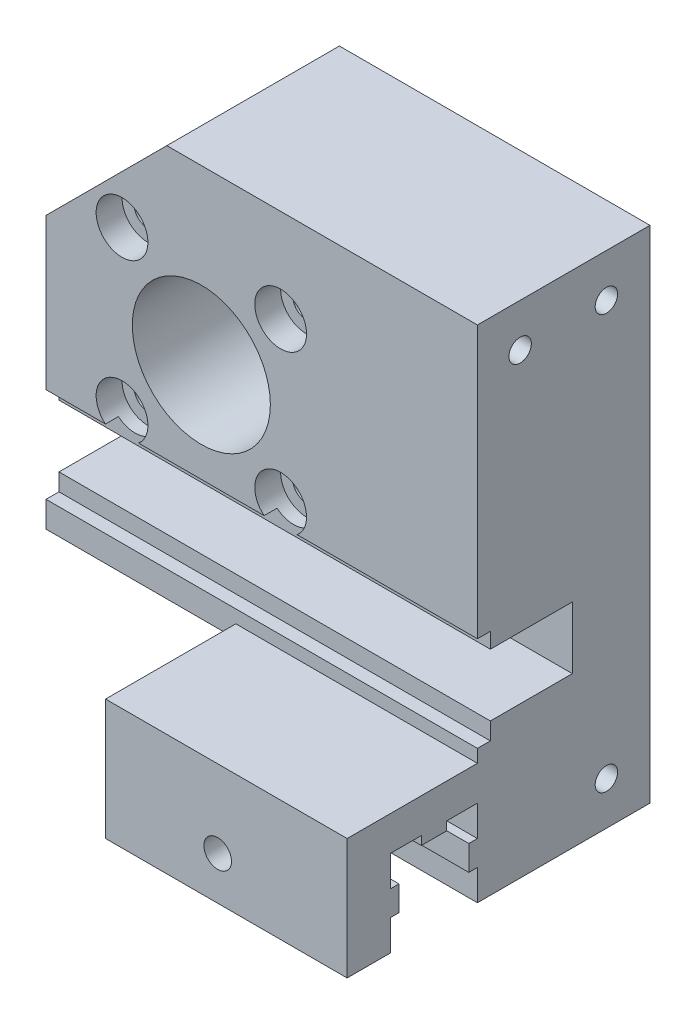
from build123d import *

# Parameters (mm, degrees)
ESQUISSE1_W                     = 50
ESQUISSE1_H                     = 45
MAIN_EXTRUSION_DEPTH            = 20
ESQUISSE5_R                     = 8
GEAR_LINEAR_HOLES_DEPTH         = 21
FIXING_EXTRUSION_DEPTH          = 25
ESQUISSE13_W                    = 50
ESQUISSE13_H                    = 7.2
ROLLINGBALLHORIZONTALHOLE_DEPTH = 11
FRONTHOLE_DEPTH                 = 22
ESQUISSE15_R                    = 1.6
BOTTOMFIXINGHOLE_DEPTH          = 36.1
ESQUISSE12_R                    = 16
REDUCTORMAINHOLE_DEPTH          = 5
REDUCTORFRONTFIXINGHOLE_DEPTH   = 3
ESQUISSE17_R                    = 1.6
MOTORFIXINGHOLE_DEPTH           = 31.1
ESQUISSE19_R                    = 3
ENL_V_MAT_EXTRU_5_DEPTH         = 3
SKETCH2_W                       = 1.5
SKETCH2_H                       = 11
CUTFORMAKERBEAMPROFILE_DEPTH    = 51
CUTFORDISTRIBUTORGRABBER_DEPTH  = 21
SKETCH4_R                       = 1.3
HOLETOBLOCKBEHIND_DEPTH         = 12


with BuildPart() as part:
    # Esquisse1 → Main Extrusion (new body)
    with BuildSketch(Plane.XY):
        Rectangle(ESQUISSE1_W, ESQUISSE1_H)
    extrude(amount=MAIN_EXTRUSION_DEPTH)

    # Esquisse5 → Gear Linear Holes (cut, through all)
    with BuildSketch(Plane.XY.offset(20)):
        with Locations((-7, 2.5)):
            Circle(ESQUISSE5_R)
    extrude(amount=-GEAR_LINEAR_HOLES_DEPTH, mode=Mode.SUBTRACT)

    # Esquisse8 → Fixing Extrusion (add, symmetric)
    with BuildSketch(Plane(origin=(0, 0, 0), x_dir=(0, 0, -1), z_dir=(1, 0, 0))):
        Polygon((-20, -25.5), (-20, -29.05), (-21, -29.05), (-21, -31.95), (-20, -31.95), (-20, -35.5), (0, -35.5), (0, -21.5), (-35.1, -21.5), (-35.1, -35.5), (-30.1, -35.5), (-30.1, -31.95), (-29.1, -31.95), (-29.1, -29.05), (-30.1, -29.05), (-30.1, -25.5), (-26.5, -25.5), (-26.5, -26.5), (-23.6, -26.5), (-23.6, -25.5), align=None)
    extrude(amount=FIXING_EXTRUSION_DEPTH, both=True)

    # Esquisse13 → RollingBallHorizontalHole (cut)
    with BuildSketch(Plane.XY.offset(20)):
        with Locations((0, -14.4)):
            Rectangle(ESQUISSE13_W, ESQUISSE13_H)
    extrude(amount=-ROLLINGBALLHORIZONTALHOLE_DEPTH, mode=Mode.SUBTRACT)

    # Esquisse14 → FrontHole (cut)
    with BuildSketch(Plane.ZY.offset(25)):
        Polygon((0, -23), (20, -23), (20, -18), (35.1, -18), (35.1, -35.5), (0, -35.5), align=None)
    extrude(amount=-FRONTHOLE_DEPTH, mode=Mode.SUBTRACT)

    # Esquisse15 → BottomFixingHole (cut, through all)
    with BuildSketch(Plane.XY.offset(35.1)):
        with Locations((10, -30.5)):
            Circle(ESQUISSE15_R)
    extrude(amount=-BOTTOMFIXINGHOLE_DEPTH, mode=Mode.SUBTRACT)

    # Esquisse12 → ReductorMainHole (cut)
    with BuildSketch(Plane.XY):
        with Locations((-7, 2.5)):
            Circle(ESQUISSE12_R)
    extrude(amount=REDUCTORMAINHOLE_DEPTH, mode=Mode.SUBTRACT)

    # Esquisse16 → ReductorFrontFixingHole (cut)
    with BuildSketch(Plane(origin=(0, 0, 5), x_dir=(-1, 0, 0), z_dir=(0, 0, -1))):
        with BuildLine():
            Line((2.641101056, 11.5), (11.358898944, 11.5))
            ThreePointArc((11.358898944, 11.5), (17, 2.5), (11.358898944, -6.5))
            Line((11.358898944, -6.5), (2.641101056, -6.5))
            ThreePointArc((2.641101056, -6.5), (-3, 2.5), (2.641101056, 11.5))
        make_face()
    extrude(amount=-REDUCTORFRONTFIXINGHOLE_DEPTH, mode=Mode.SUBTRACT)

    # Esquisse17 → MotorFixingHole (cut, through all)
    with BuildSketch(Plane(origin=(0, 0, 5), x_dir=(-1, 0, 0), z_dir=(0, 0, -1))):
        with Locations((-2.192388155, 11.692388155)):
            Circle(ESQUISSE17_R)
        with Locations((16.192388155, 11.692388155)):
            Circle(ESQUISSE17_R)
        with Locations((-2.192388155, -6.692388155)):
            Circle(ESQUISSE17_R)
        with Locations((16.192388155, -6.692388155)):
            Circle(ESQUISSE17_R)
    extrude(amount=-MOTORFIXINGHOLE_DEPTH, mode=Mode.SUBTRACT)

    # Esquisse19 → Enlèv. mat.-Extru.5 (cut)
    with BuildSketch(Plane.XY.offset(20)):
        with Locations((-16.192388155, 11.692388155)):
            Circle(ESQUISSE19_R)
        with Locations((2.192388155, 11.692388155)):
            Circle(ESQUISSE19_R)
        with Locations((-16.192388155, -6.692388155)):
            Circle(ESQUISSE19_R)
        with Locations((2.192388155, -6.692388155)):
            Circle(ESQUISSE19_R)
    extrude(amount=-ENL_V_MAT_EXTRU_5_DEPTH, mode=Mode.SUBTRACT)

    # Sketch2 → CutForMakerBeamProfile (cut, through all)
    with BuildSketch(Plane(origin=(25, 0, 0), x_dir=(0, 0, -1), z_dir=(1, 0, 0))):
        with Locations((-19.25, -14.5)):
            Rectangle(SKETCH2_W, SKETCH2_H)
    extrude(amount=-CUTFORMAKERBEAMPROFILE_DEPTH, mode=Mode.SUBTRACT)

    # Sketch3 → CutForDistributorGrabber (cut, through all)
    with BuildSketch(Plane.XY.offset(20)):
        Polygon((-11, 22.5), (-25, 8.5), (-25, 22.5), align=None)
    extrude(amount=-CUTFORDISTRIBUTORGRABBER_DEPTH, mode=Mode.SUBTRACT)

    # Sketch4 → HoleToBlockBehind (cut)
    with BuildSketch(Plane(origin=(25, 0, 0), x_dir=(0, 0, -1), z_dir=(1, 0, 0))):
        with Locations((-5.05, -30.5)):
            Circle(SKETCH4_R)
        with Locations((-25.05, -30.5)):
            Circle(SKETCH4_R)
        with Locations((-5.05, 17.5)):
            Circle(SKETCH4_R)
        with Locations((-15.05, 17.5)):
            Circle(SKETCH4_R)
    extrude(amount=-HOLETOBLOCKBEHIND_DEPTH, mode=Mode.SUBTRACT)


solid = part.part
